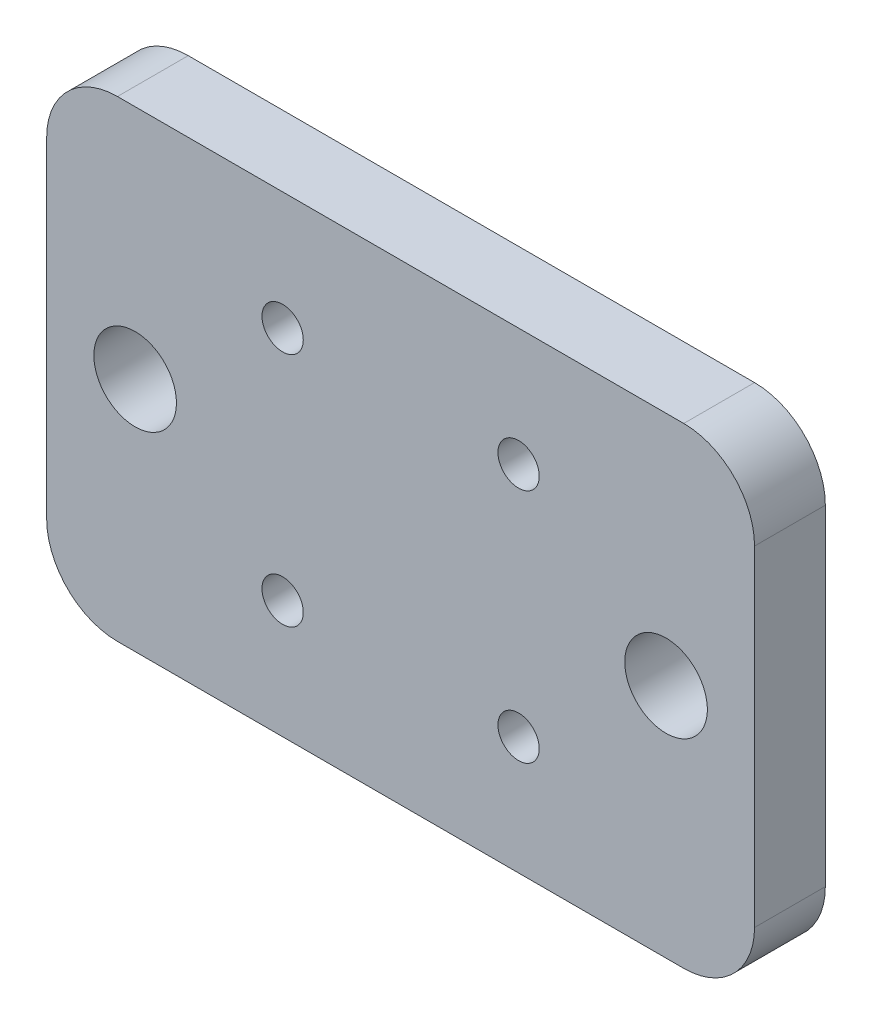
from build123d import *

# Parameters (mm, degrees)
ESQUISSE1_W                  = 60
ESQUISSE1_H                  = 40
BOSS_EXTRU_1_DEPTH           = 6
ESQUISSE2_R                  = 1.75
ESQUISSE2_R_2                = 3.5
ENL_V_MAT_EXTRU_1_DEPTH      = 1
ENL_V_MAT_EXTRU_1_DEPTH_BACK = 7
CONG_1_R                     = 6


with BuildPart() as part:
    # Esquisse1 → Boss.-Extru.1 (new body)
    with BuildSketch(Plane.XY):
        with Locations((30, 20)):
            Rectangle(ESQUISSE1_W, ESQUISSE1_H)
    extrude(amount=BOSS_EXTRU_1_DEPTH)

    # Esquisse2 → Enlèv. mat.-Extru.1 (cut, two sides)
    with BuildSketch(Plane.XY.offset(6)) as enl_v_mat_extru_1_sk:
        with Locations((20, 30)):
            Circle(ESQUISSE2_R)
        with Locations((40, 30)):
            Circle(ESQUISSE2_R)
        with Locations((40, 10)):
            Circle(ESQUISSE2_R)
        with Locations((20, 10)):
            Circle(ESQUISSE2_R)
        with Locations((7.5, 20)):
            Circle(ESQUISSE2_R_2)
        with Locations((52.5, 20)):
            Circle(ESQUISSE2_R_2)
    extrude(amount=ENL_V_MAT_EXTRU_1_DEPTH, mode=Mode.SUBTRACT)
    extrude(enl_v_mat_extru_1_sk.sketch, amount=-ENL_V_MAT_EXTRU_1_DEPTH_BACK, mode=Mode.SUBTRACT)

    # Congé1
    cong_1_edges = [part.edges().sort_by_distance(p)[0] for p in [
        (0, 40, 3),
        (60, 40, 3),
        (60, 0, 3),
        (0, 0, 3),
    ]]
    fillet(cong_1_edges, radius=CONG_1_R)


solid = part.part
